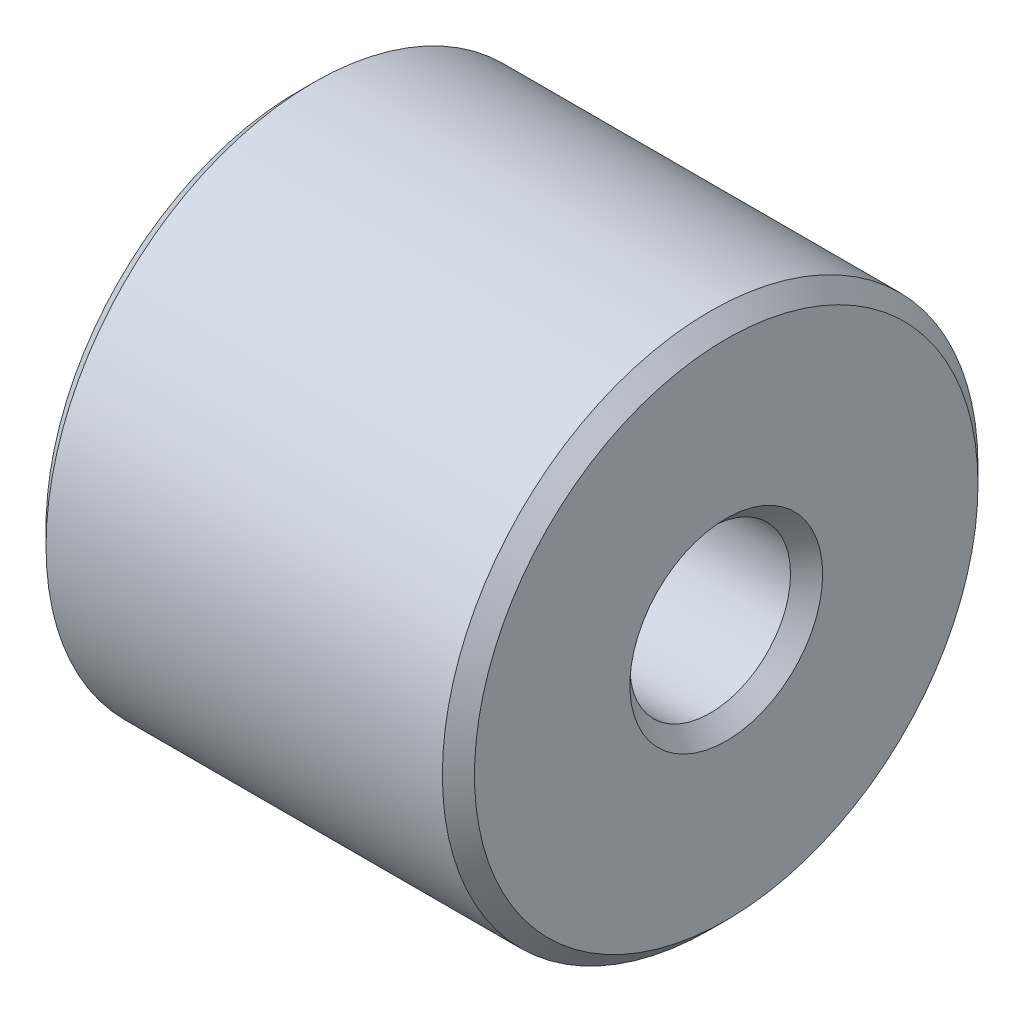
from build123d import *

# Parameters (mm, degrees)
SKETCH1_R           = 2.5
SKETCH1_R_2         = 0.75
BOSS_EXTRUDE1_DEPTH = 4
CHAMFER1_SIZE       = 0.15


with BuildPart() as part:
    # Sketch1 → Boss-Extrude1 (new body)
    with BuildSketch(Plane(origin=(0, 0, 0), x_dir=(0, 0, -1), z_dir=(1, 0, 0))):
        Circle(SKETCH1_R)
        Circle(SKETCH1_R_2, mode=Mode.SUBTRACT)
    extrude(amount=BOSS_EXTRUDE1_DEPTH)

    # Chamfer1
    chamfer1_edges = [part.edges().sort_by_distance(p)[0] for p in [
        (0, 0, 2.5),
        (4, 0, 2.5),
        (0, 0, 0.75),
        (4, 0, 0.75),
    ]]
    chamfer(chamfer1_edges, length=CHAMFER1_SIZE)


solid = part.part
